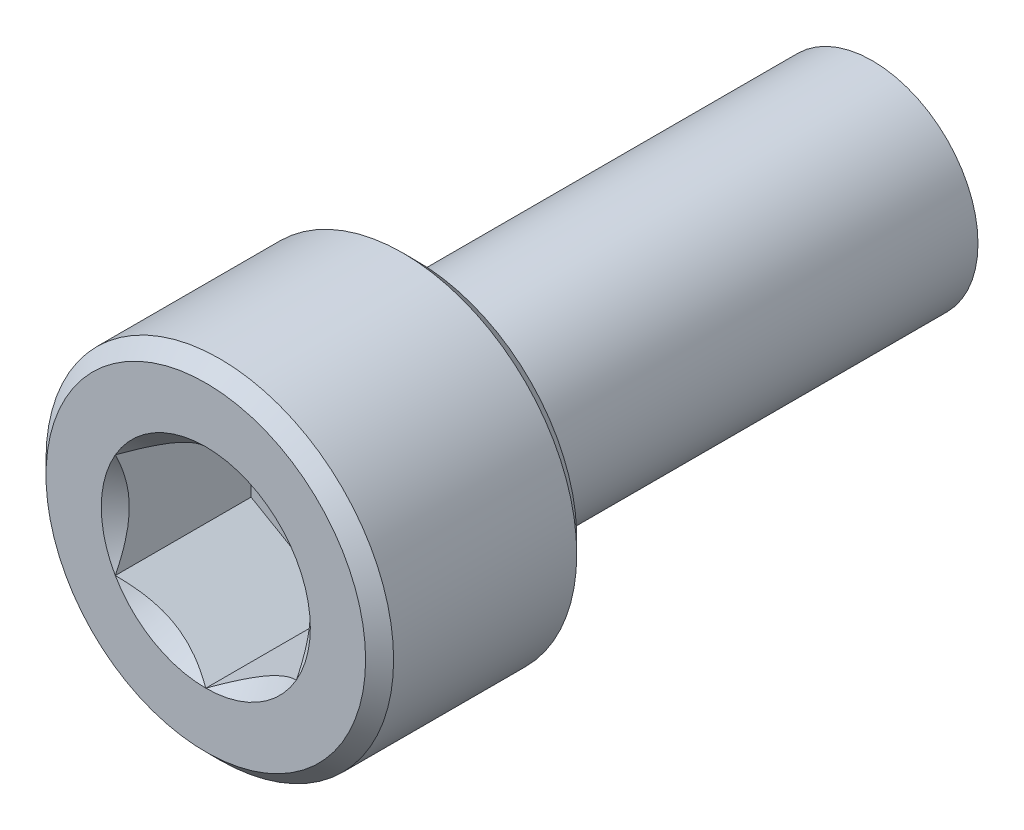
from build123d import *

# Parameters (mm, degrees)
SKETCH1_W           = 3.429
SKETCH1_H           = 4.1656
SKETCH2_R           = 2.0828
BOSS_EXTRUDE1_DEPTH = 9.525
CUT_EXTRUDE1_DEPTH  = 2.678906
CHAMFER1_SIZE       = 0.27628549
CHAMFER2_SIZE       = 0.769555748
CHAMFER2_SIZE2      = 0.538848736


with BuildPart() as part:
    # Sketch1 → Revolve1 (revolve)
    with BuildSketch(Plane.XZ):
        with Locations((12.082710259, 4.5828)):
            Rectangle(SKETCH1_W, SKETCH1_H)
    revolve(axis=Axis((10.368210259, 0, 6.6656), (0, 0, -1)))

    # Sketch2 → Boss-Extrude1 (add)
    with BuildSketch(Plane(origin=(0, 0, 2.5), x_dir=(-1, 0, 0), z_dir=(0, 0, -1))):
        with Locations((-10.368210259, 0)):
            Circle(SKETCH2_R)
    extrude(amount=BOSS_EXTRUDE1_DEPTH)

    # Sketch3 → Cut-Extrude1 (cut)
    with BuildSketch(Plane(origin=(0, 0, 3.98669375), x_dir=(-1, 0, 0), z_dir=(0, 0, -1))):
        Polygon((-10.368210259, -2.062222993), (-8.582272759, -1.031111496), (-8.582272759, 1.031111496), (-10.368210259, 2.062222993), (-12.154147759, 1.031111496), (-12.154147759, -1.031111496), align=None)
    extrude(amount=-CUT_EXTRUDE1_DEPTH, mode=Mode.SUBTRACT)

    # Chamfer1
    chamfer1_edges = [part.edges().sort_by_distance(p)[0] for p in [
        (6.939210259, 0, 2.5),
        (6.939210259, 0, 6.6656),
    ]]
    chamfer(chamfer1_edges, length=CHAMFER1_SIZE)

    # Chamfer2
    chamfer2_edges = [part.edges().sort_by_distance(p)[0] for p in [
        (12.451010259, 0, -7.025),
    ]]
    chamfer2_side = [part.faces().sort_by_distance(p)[0] for p in [
        (10.368210259, 0, -7.025),
    ]]
    chamfer(chamfer2_edges, length=CHAMFER2_SIZE, length2=CHAMFER2_SIZE2, reference=chamfer2_side[0])

    # Sketch4 → Cut-Revolve1 (revolve, cut)
    with BuildSketch(Plane(origin=(0, 0, 0), x_dir=(1, 0, 0), z_dir=(0, 1, 0))):
        Polygon((8.582272759, -6.38931451), (8.305987269, -6.6656), (8.582272759, -6.6656), align=None)
    revolve(axis=Axis((10.368210259, 0, 6.799545312), (0, 0, -1)), mode=Mode.SUBTRACT)


solid = part.part
